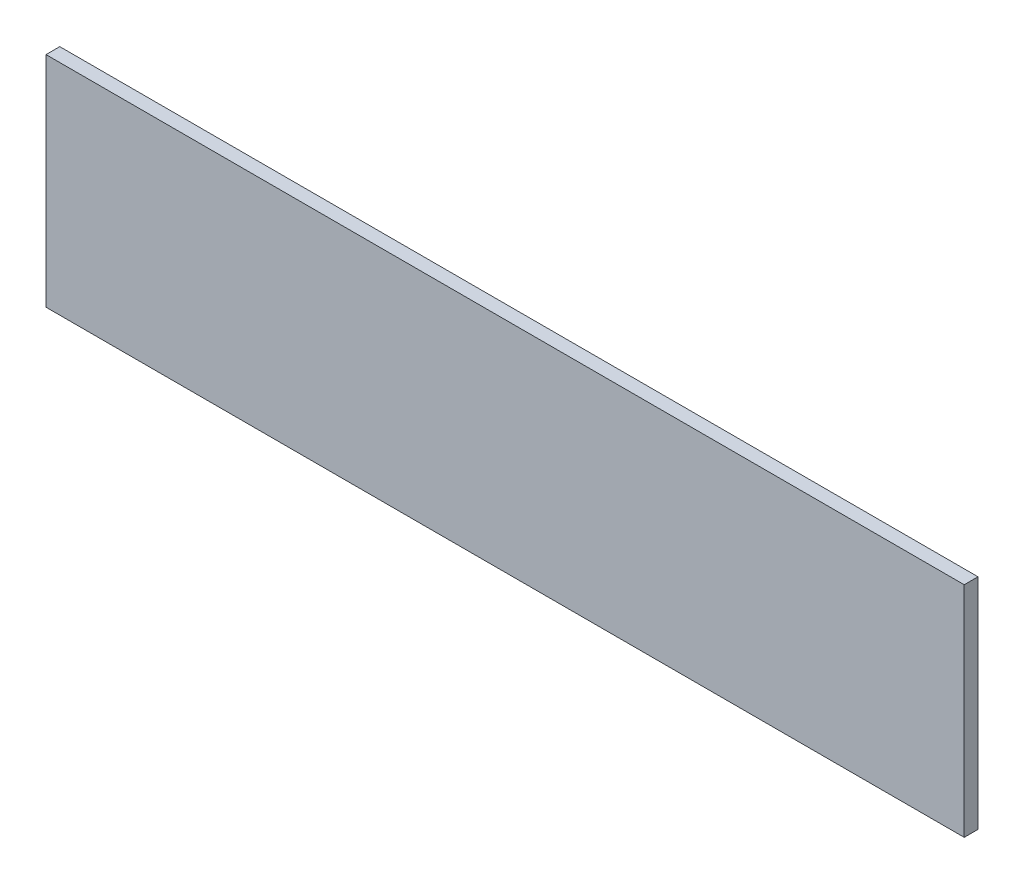
from build123d import *

# Parameters (mm, degrees)
ESQUISSE1_W        = 200
ESQUISSE1_H        = 47.657925926
BOSS_EXTRU_1_DEPTH = 3


with BuildPart() as part:
    # Esquisse1 → Boss.-Extru.1 (new body)
    with BuildSketch(Plane.XY):
        with Locations((41.091419201, 10.555111111)):
            Rectangle(ESQUISSE1_W, ESQUISSE1_H)
    extrude(amount=BOSS_EXTRU_1_DEPTH)


solid = part.part
